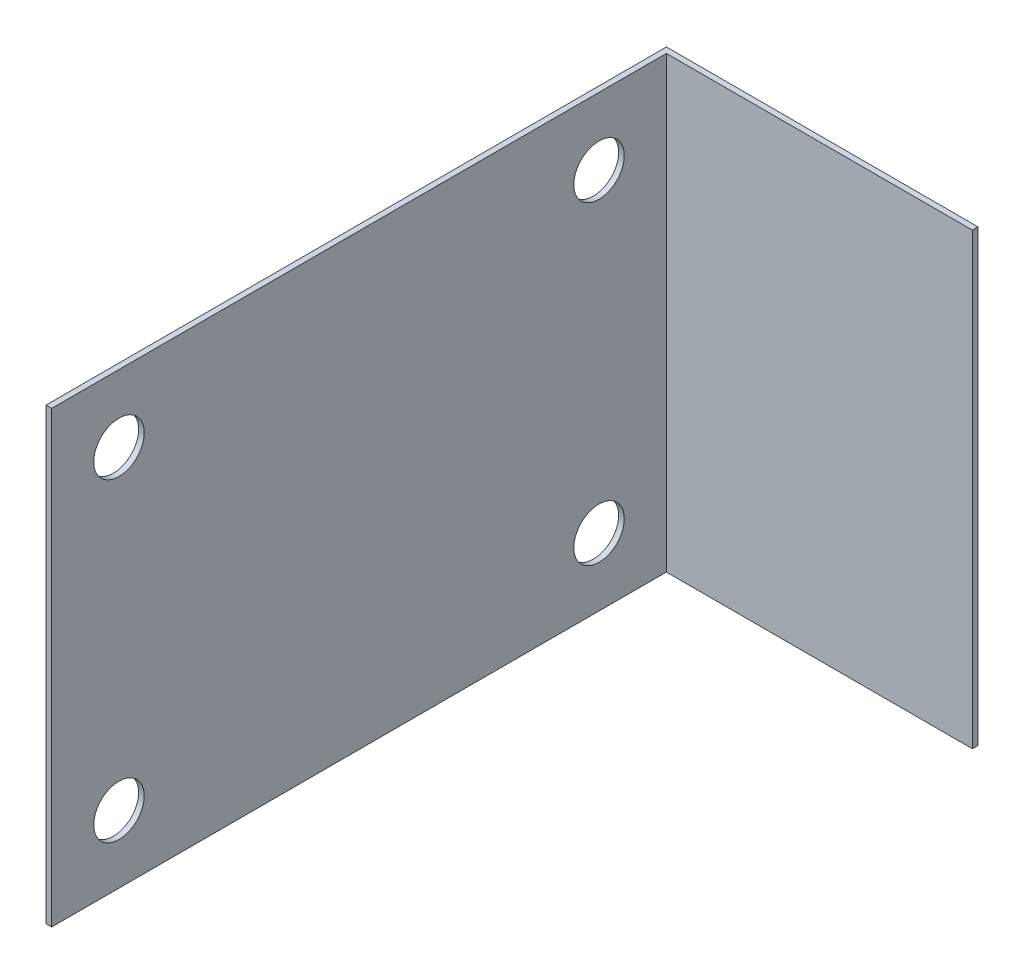
from build123d import *

# Parameters (mm, degrees)
BOSS_EXTRUDE1_DEPTH = 127
SKETCH2_R           = 14.2748
CUT_EXTRUDE1_DEPTH  = 4.175


with BuildPart() as part:
    # Sketch1 → Boss-Extrude1 (new body, symmetric)
    with BuildSketch(Plane(origin=(0, 0, 0), x_dir=(1, 0, 0), z_dir=(0, 1, 0))):
        Polygon((0, 0), (3.175, 0), (3.175, 347.6625), (176.2125, 347.6625), (176.2125, 350.8375), (0, 350.8375), align=None)
    extrude(amount=BOSS_EXTRUDE1_DEPTH, both=True)

    # Sketch2 → Cut-Extrude1 (cut, through all)
    with BuildSketch(Plane(origin=(3.175, 0, 0), x_dir=(0, 0, -1), z_dir=(1, 0, 0))):
        with Locations((309.5625, -88.9)):
            Circle(SKETCH2_R)
        with Locations((309.5625, 88.9)):
            Circle(SKETCH2_R)
        with Locations((38.1, -88.9)):
            Circle(SKETCH2_R)
        with Locations((38.1, 88.9)):
            Circle(SKETCH2_R)
    extrude(amount=-CUT_EXTRUDE1_DEPTH, mode=Mode.SUBTRACT)


solid = part.part
